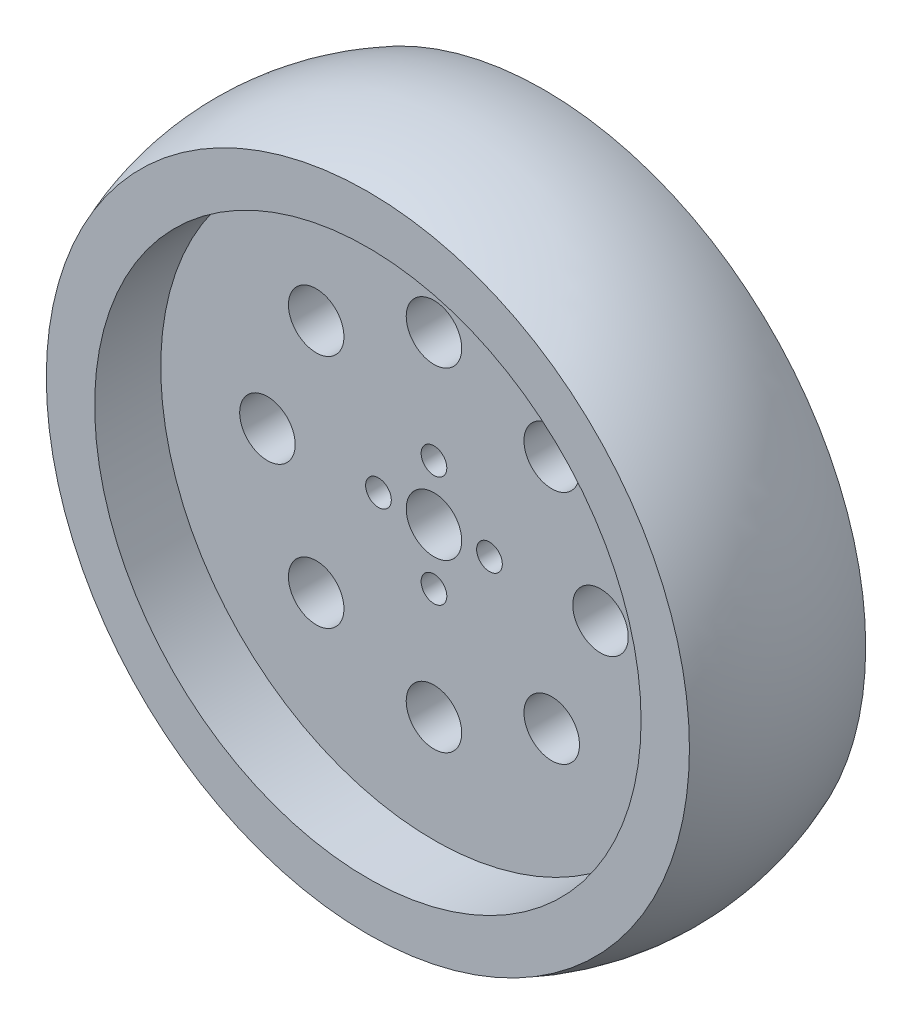
from build123d import *

# Parameters (mm, degrees)
F_8_0_8_DIAMETER_HOLE1_D       = 8
F_8_0_8_DIAMETER_HOLE1_DEPTH   = 15.875
F_3_7_3_7_DIAMETER_HOLE1_D     = 3.7
F_3_7_3_7_DIAMETER_HOLE1_DEPTH = 15.875


with BuildPart() as part:
    # Sketch1 → Revolve1 (revolve)
    with BuildSketch(Plane(origin=(0, 0, 0), x_dir=(1, 0, 0), z_dir=(0, 1, 0))):
        with BuildLine():
            Line((46.339023447, 12.7), (0, 12.7))
            Line((0, 12.7), (0, -12.7))
            Line((0, -12.7), (46.339023447, -12.7))
            ThreePointArc((46.339023447, -12.7), (48.8, 0), (46.339023447, 12.7))
        make_face()
    revolve(axis=Axis((0, 0, -12.7), (0, 0, 1)))

    # Sketch2 → Cut-Revolve1 (revolve, cut)
    with BuildSketch(Plane(origin=(0, 0, 0), x_dir=(1, 0, 0), z_dir=(0, 1, 0))):
        Polygon((39.37, 12.7), (0, 12.7), (0, -12.7), (39.37, -12.7), (39.37, -3.175), (4, -3.175), (4, 3.175), (39.37, 3.175), align=None)
    revolve(axis=Axis((0, 0, -12.7), (0, 0, 1)), mode=Mode.SUBTRACT)

    # Ø8.0 (8) Diameter Hole1
    with Locations(Plane(origin=(0, 0, -3.175), x_dir=(-1, 0, 0), z_dir=(0, 0, -1))):
        with Locations((0, -24), (-16.970562748, -16.970562748), (-24, 0), (-16.970562748, 16.970562748), (0, 24), (16.970562748, 16.970562748), (24, 0), (16.970562748, -16.970562748)):
            Hole(F_8_0_8_DIAMETER_HOLE1_D / 2, depth=F_8_0_8_DIAMETER_HOLE1_DEPTH)

    # Ø3.7 (3.7) Diameter Hole1
    with Locations(Plane(origin=(0, 0, -3.175), x_dir=(-1, 0, 0), z_dir=(0, 0, -1))):
        with Locations((-8, 0), (0, -8), (8, 0), (0, 8)):
            Hole(F_3_7_3_7_DIAMETER_HOLE1_D / 2, depth=F_3_7_3_7_DIAMETER_HOLE1_DEPTH)


solid = part.part
